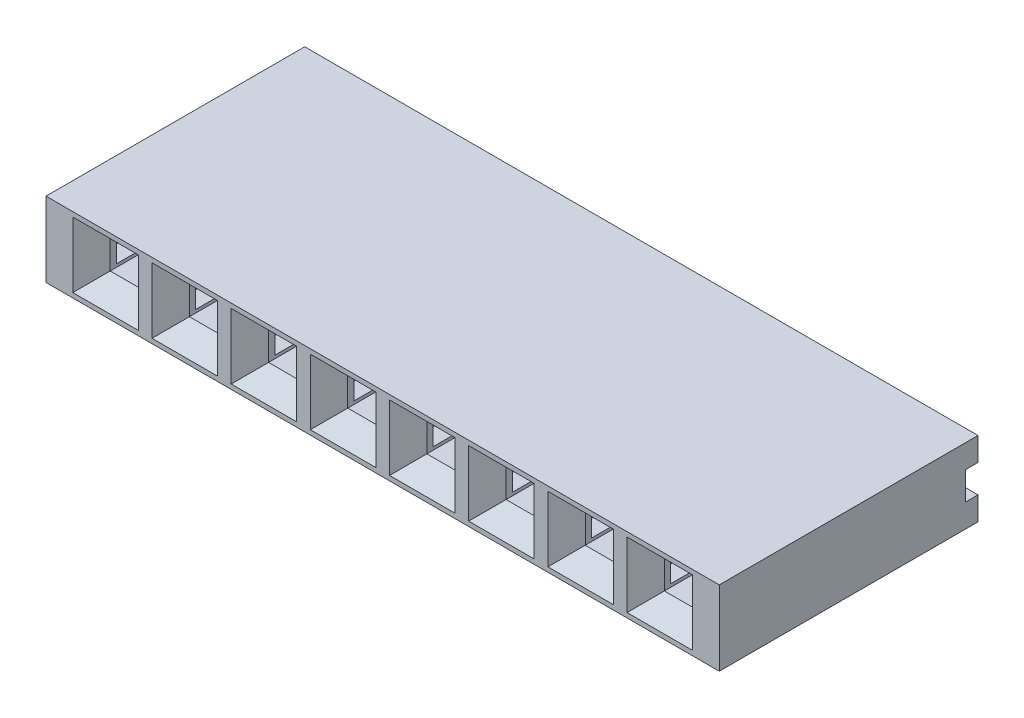
from build123d import *

# Parameters (mm, degrees)
SKETCH_222_W              = 2.54
SKETCH_222_H              = 2.4
EXTRUDE_699_DEPTH         = 6.7
EXTRUDE_699_DEPTH_BACK    = 0.4
SKETCH_753_W              = 2.54
SKETCH_753_H              = 0.75
EXTRUDE_1132_DEPTH        = 0.4
SKETCH_1186_W             = 2.54
SKETCH_1186_H             = 2.4
SKETCH_1186_W_2           = 0.9
SKETCH_1186_H_2           = 0.9
EXTRUDE_1471_DEPTH        = 0.8
CHAMFER_1532_SIZE         = 0.6
PATTERN_LINEAR_1658_COUNT = 8
PATTERN_LINEAR_1658_PITCH = 2.54
EXTRUDE_1_DEPTH           = 0.64
EXTRUDE_START             = -20.96
EXTRUDE_2_DEPTH           = 0.64


with BuildPart() as part:
    # Sketch 222 → Extrude 699 (new body, two sides)
    with BuildSketch(Plane.XY) as extrude_699_sk:
        Rectangle(SKETCH_222_W, SKETCH_222_H)
        Polygon((-1, 0.35), (-0.45, 0.35), (-0.45, 0.45), (0.45, 0.45), (0.45, 0.35), (1, 0.35), (1, -0.35), (0.45, -0.35), (0.45, -0.45), (-0.45, -0.45), (-0.45, -0.35), (-1, -0.35), align=None, mode=Mode.SUBTRACT)
    extrude(amount=EXTRUDE_699_DEPTH)
    extrude(extrude_699_sk.sketch, amount=-EXTRUDE_699_DEPTH_BACK)

    # Sketch 753 → Extrude 1132 (add)
    with BuildSketch(Plane(origin=(0, 0, -0.4), x_dir=(-1, 0, 0), z_dir=(0, 0, -1))):
        with Locations((0, -0.825)):
            Rectangle(SKETCH_753_W, SKETCH_753_H)
        with Locations((0, 0.825)):
            Rectangle(SKETCH_753_W, SKETCH_753_H)
    extrude(amount=EXTRUDE_1132_DEPTH)

    # Sketch 1186 → Extrude 1471 (add)
    with BuildSketch(Plane.XY.offset(6.7)):
        Rectangle(SKETCH_1186_W, SKETCH_1186_H)
        Rectangle(SKETCH_1186_W_2, SKETCH_1186_H_2, mode=Mode.SUBTRACT)
    extrude(amount=EXTRUDE_1471_DEPTH)

    # Chamfer 1532
    chamfer_1532_edges = [part.edges().sort_by_distance(p)[0] for p in [
        (0.45, 0, 7.5),
        (0, 0.45, 7.5),
        (-0.45, 0, 7.5),
        (0, -0.45, 7.5),
    ]]
    chamfer(chamfer_1532_edges, length=CHAMFER_1532_SIZE)


with BuildPart() as pattern_linear_1658_1:
    # Pattern Linear 1658: pattern copy
    add(part.part.moved(Location(Vector(-1, 0, 0) * (1 * PATTERN_LINEAR_1658_PITCH))))


with BuildPart() as pattern_linear_1658_2:
    # Pattern Linear 1658: pattern copy
    add(part.part.moved(Location(Vector(-1, 0, 0) * (2 * PATTERN_LINEAR_1658_PITCH))))


with BuildPart() as pattern_linear_1658_3:
    # Pattern Linear 1658: pattern copy
    add(part.part.moved(Location(Vector(-1, 0, 0) * (3 * PATTERN_LINEAR_1658_PITCH))))


with BuildPart() as pattern_linear_1658_4:
    # Pattern Linear 1658: pattern copy
    add(part.part.moved(Location(Vector(-1, 0, 0) * (4 * PATTERN_LINEAR_1658_PITCH))))


with BuildPart() as pattern_linear_1658_5:
    # Pattern Linear 1658: pattern copy
    add(part.part.moved(Location(Vector(-1, 0, 0) * (5 * PATTERN_LINEAR_1658_PITCH))))


with BuildPart() as pattern_linear_1658_6:
    # Pattern Linear 1658: pattern copy
    add(part.part.moved(Location(Vector(-1, 0, 0) * (6 * PATTERN_LINEAR_1658_PITCH))))


with BuildPart() as pattern_linear_1658_7:
    # Pattern Linear 1658: pattern copy
    add(part.part.moved(Location(Vector(-1, 0, 0) * (7 * PATTERN_LINEAR_1658_PITCH))))


with BuildPart() as part_1:
    add(part.part)

    # Combine 1774: union Pattern Linear 1658_7, Pattern Linear 1658_6, Pattern Linear 1658_5, Pattern Linear 1658_4, Pattern Linear 1658_3, Pattern Linear 1658_2, Pattern Linear 1658_1
    add(pattern_linear_1658_7.part)
    add(pattern_linear_1658_6.part)
    add(pattern_linear_1658_5.part)
    add(pattern_linear_1658_4.part)
    add(pattern_linear_1658_3.part)
    add(pattern_linear_1658_2.part)
    add(pattern_linear_1658_1.part)

    # Sketch 2582 → Бобышка-БоковаяНакладка1 (add)
    with BuildSketch(Plane(origin=(1.27, 0, 0), x_dir=(0, 0, -1), z_dir=(1, 0, 0))):
        Polygon((0.8, 1.2), (0.8, 0.45), (0.4, 0.45), (0.4, -0.45), (0.8, -0.45), (0.8, -1.2), (-7.5, -1.2), (-7.5, 1.2), align=None)
    extrude(amount=EXTRUDE_1_DEPTH)

    # Эскиз-БоковаяНакладка<2> → Бобышка-БоковаяНакладка2 (add)
    with BuildSketch(Plane(origin=(1.27, 0, 0), x_dir=(0, 0, -1), z_dir=(1, 0, 0)).offset(EXTRUDE_START)):
        Polygon((0.8, 1.2), (0.8, 0.45), (0.4, 0.45), (0.4, -0.45), (0.8, -0.45), (0.8, -1.2), (-7.5, -1.2), (-7.5, 1.2), align=None)
    extrude(amount=EXTRUDE_2_DEPTH)


solid = part_1.part
